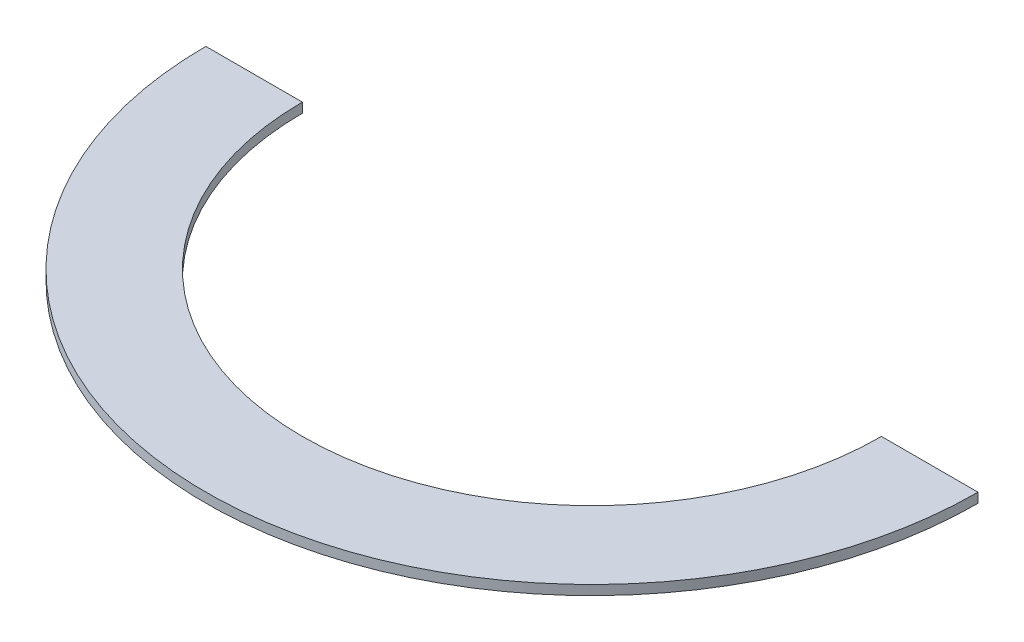
from build123d import *

# Parameters (mm, degrees)
EXTRUSION1_DEPTH = 10


with BuildPart() as part:
    # Esquisse1 → Extrusion1 (new body)
    with BuildSketch(Plane(origin=(0, 0, 0), x_dir=(1, 0, 0), z_dir=(0, 1, 0))):
        with BuildLine():
            Line((0, 0), (100, 0))
            ThreePointArc((100, 0), (400, -300), (700, 0))
            Line((700, 0), (800, 0))
            ThreePointArc((800, 0), (400, -400), (0, 0))
        make_face()
    extrude(amount=EXTRUSION1_DEPTH)


solid = part.part
